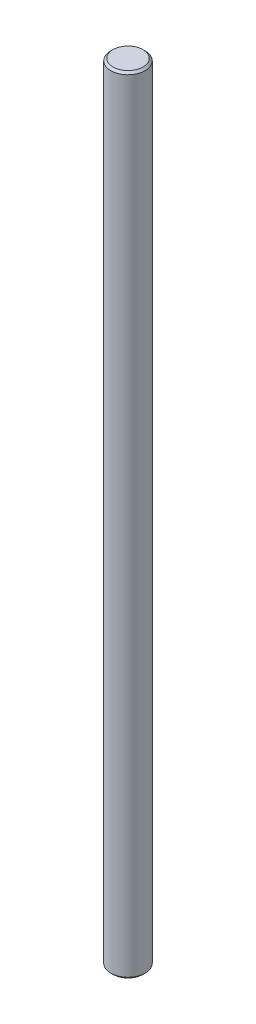
from build123d import *


with BuildPart() as part:
    # Sketch1 → Revolve1 (revolve)
    with BuildSketch(Plane.XY):
        Polygon((8, -182), (8, 182), (7, 183), (0, 183), (0, -183), (7, -183), align=None)
    revolve(axis=Axis((0, 183, 0), (0, -1, 0)))


solid = part.part
